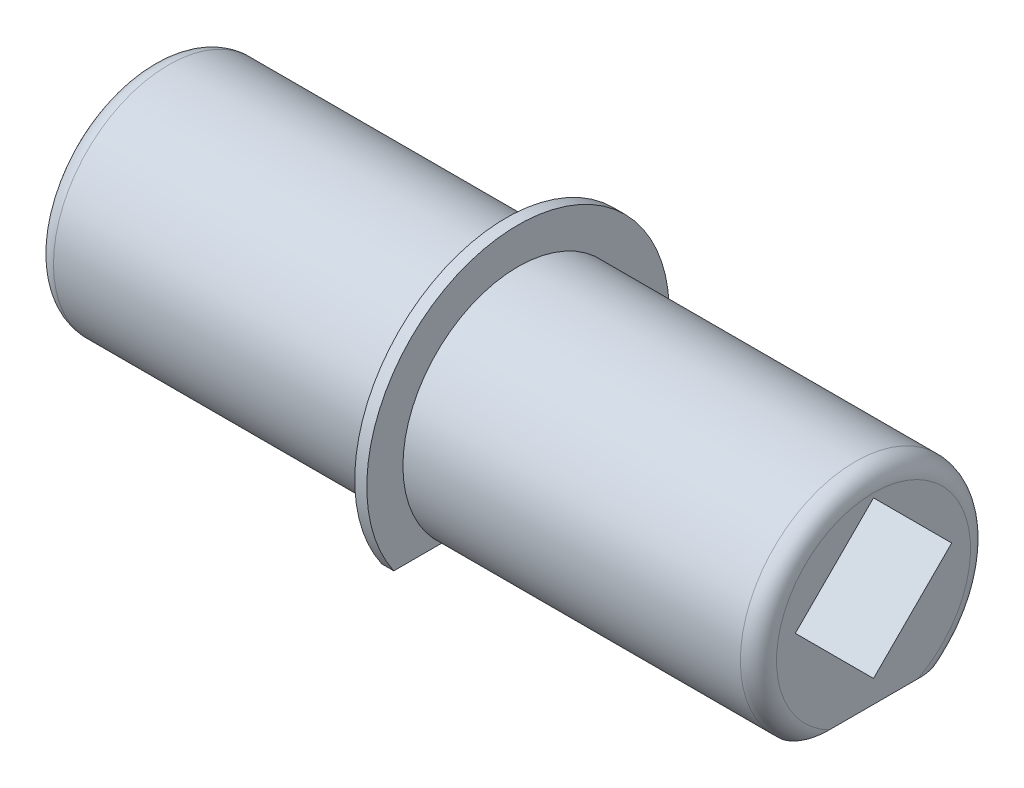
from build123d import *

# Parameters (mm, degrees)
BOSS_EXTRU_1_DEPTH      = 30
BOSS_EXTRU_2_DEPTH      = 0.5
ENL_V_MAT_EXTRU_1_DEPTH = 50
CONG_1_R                = 1.5


with BuildPart() as part:
    # Esquisse1 → Boss.-Extru.1 (new body, symmetric)
    with BuildSketch(Plane(origin=(0, 0, 0), x_dir=(0, 0, -1), z_dir=(1, 0, 0))):
        with BuildLine():
            Line((-6.318486634, -7.160951519), (6.318486634, -7.160951519))
            ThreePointArc((6.318486634, -7.160951519), (0, 9.55), (-6.318486634, -7.160951519))
        make_face()
    extrude(amount=BOSS_EXTRU_1_DEPTH, both=True)

    # Esquisse3 → Boss.-Extru.2 (add, symmetric)
    with BuildSketch(Plane(origin=(0, 0, 0), x_dir=(0, 0, -1), z_dir=(1, 0, 0))):
        with BuildLine():
            Line((-10.306467549, -7.160951519), (10.306467549, -7.160951519))
            ThreePointArc((10.306467549, -7.160951519), (0, 12.55), (-10.306467549, -7.160951519))
        make_face()
    extrude(amount=BOSS_EXTRU_2_DEPTH, both=True)

    # Esquisse2 → Enlèv. mat.-Extru.1 (cut, symmetric)
    with BuildSketch(Plane(origin=(0, 0, 0), x_dir=(0, 0, -1), z_dir=(1, 0, 0))):
        Polygon((-6.488442747, 1.194524241), (0, -5.293918507), (6.488442747, 1.194524241), (0, 7.682966988), align=None)
    extrude(amount=ENL_V_MAT_EXTRU_1_DEPTH, both=True, mode=Mode.SUBTRACT)

    # Congé1
    cong_1_edges = [part.edges().sort_by_distance(p)[0] for p in [
        (-30, 9.55, 0),
        (30, 9.55, 0),
    ]]
    fillet(cong_1_edges, radius=CONG_1_R)


solid = part.part
